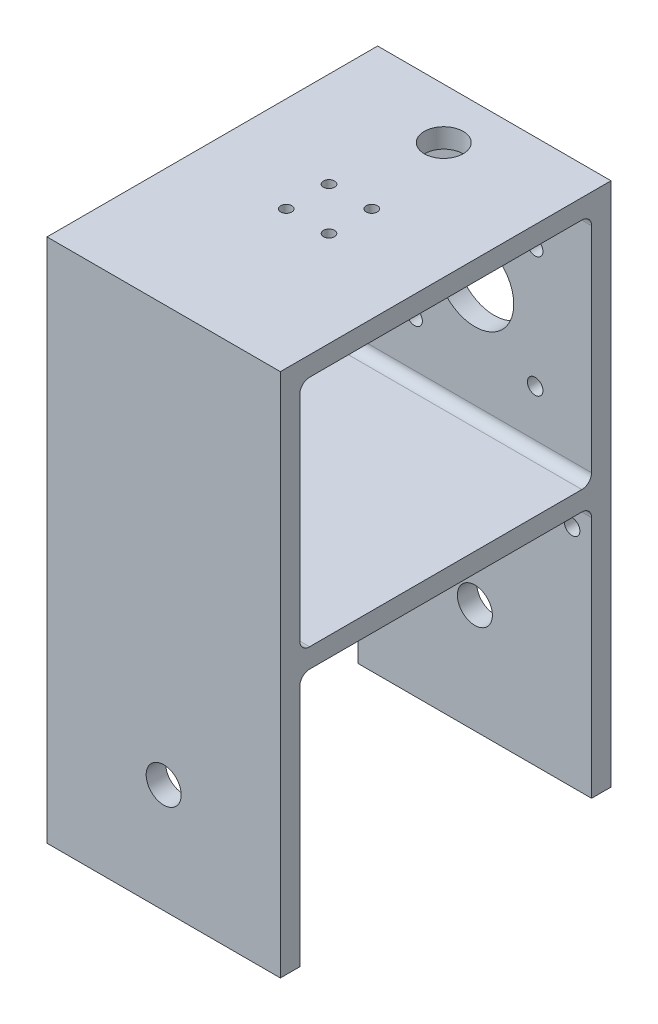
from build123d import *

# Parameters (mm, degrees)
BOSS_EXTRUDE1_DEPTH = 60
SKETCH2_W           = 75
SKETCH2_H           = 60
CUT_EXTRUDE1_DEPTH  = 60
CUT_EXTRUDE2_REACH  = 137
SKETCH3_R           = 1.425
SKETCH3_R_2         = 5
CUT_EXTRUDE3_REACH  = 87
SKETCH4_R           = 4.5
SKETCH4_R_2         = 10
SKETCH4_R_3         = 2
FILLET1_R           = 2.5
FILLET2_R           = 2.5
FILLET3_R           = 2.5
FILLET4_R           = 2.5
FILLET5_R           = 2.5
FILLET6_R           = 2.5
CUT_EXTRUDE4_REACH  = 87
SKETCH5_R           = 4.5


with BuildPart() as part:
    # Sketch1 → Boss-Extrude1 (new body)
    with BuildSketch(Plane(origin=(0, 0, 0), x_dir=(0, 0, -1), z_dir=(1, 0, 0))):
        Polygon((0, 0), (0, -135), (-5, -135), (-5, -70), (-80, -70), (-80, -135), (-85, -135), (-85, 0), align=None)
    extrude(amount=-BOSS_EXTRUDE1_DEPTH)

    # Sketch2 → Cut-Extrude1 (cut)
    with BuildSketch(Plane(origin=(0, 0, 0), x_dir=(0, 0, -1), z_dir=(1, 0, 0))):
        with Locations((-42.5, -35)):
            Rectangle(SKETCH2_W, SKETCH2_H)
    extrude(amount=-CUT_EXTRUDE1_DEPTH, mode=Mode.SUBTRACT)

    # Sketch3 → Cut-Extrude2 (cut, up to next)
    with BuildSketch(Plane(origin=(0, 0, 0), x_dir=(1, 0, 0), z_dir=(0, 1, 0)), mode=Mode.PRIVATE) as cut_extrude2_sk1:
        with Locations((-35.5, -37)):
            Circle(SKETCH3_R)
    cut_extrude2_tool1 = extrude(cut_extrude2_sk1.sketch, amount=-CUT_EXTRUDE2_REACH, mode=Mode.PRIVATE) & part.part
    add(cut_extrude2_tool1.solids().sort_by_distance((-35.5, 0, 37))[0], mode=Mode.SUBTRACT)
    # Sketch3 → Cut-Extrude2 (cut, up to next)
    with BuildSketch(Plane(origin=(0, 0, 0), x_dir=(1, 0, 0), z_dir=(0, 1, 0)), mode=Mode.PRIVATE) as cut_extrude2_sk2:
        with Locations((-24.5, -37)):
            Circle(SKETCH3_R)
    cut_extrude2_tool2 = extrude(cut_extrude2_sk2.sketch, amount=-CUT_EXTRUDE2_REACH, mode=Mode.PRIVATE) & part.part
    add(cut_extrude2_tool2.solids().sort_by_distance((-24.5, 0, 37))[0], mode=Mode.SUBTRACT)
    # Sketch3 → Cut-Extrude2 (cut, up to next)
    with BuildSketch(Plane(origin=(0, 0, 0), x_dir=(1, 0, 0), z_dir=(0, 1, 0)), mode=Mode.PRIVATE) as cut_extrude2_sk3:
        with Locations((-24.5, -48)):
            Circle(SKETCH3_R)
    cut_extrude2_tool3 = extrude(cut_extrude2_sk3.sketch, amount=-CUT_EXTRUDE2_REACH, mode=Mode.PRIVATE) & part.part
    add(cut_extrude2_tool3.solids().sort_by_distance((-24.5, 0, 48))[0], mode=Mode.SUBTRACT)
    # Sketch3 → Cut-Extrude2 (cut, up to next)
    with BuildSketch(Plane(origin=(0, 0, 0), x_dir=(1, 0, 0), z_dir=(0, 1, 0)), mode=Mode.PRIVATE) as cut_extrude2_sk4:
        with Locations((-35.5, -48)):
            Circle(SKETCH3_R)
    cut_extrude2_tool4 = extrude(cut_extrude2_sk4.sketch, amount=-CUT_EXTRUDE2_REACH, mode=Mode.PRIVATE) & part.part
    add(cut_extrude2_tool4.solids().sort_by_distance((-35.5, 0, 48))[0], mode=Mode.SUBTRACT)
    # Sketch3 → Cut-Extrude2 (cut, up to next)
    with BuildSketch(Plane(origin=(0, 0, 0), x_dir=(1, 0, 0), z_dir=(0, 1, 0)), mode=Mode.PRIVATE) as cut_extrude2_sk5:
        with Locations((-30, -13)):
            Circle(SKETCH3_R_2)
    cut_extrude2_tool5 = extrude(cut_extrude2_sk5.sketch, amount=-CUT_EXTRUDE2_REACH, mode=Mode.PRIVATE) & part.part
    add(cut_extrude2_tool5.solids().sort_by_distance((-30, 0, 13))[0], mode=Mode.SUBTRACT)

    # Sketch4 → Cut-Extrude3 (cut, up to next)
    with BuildSketch(Plane.XY, mode=Mode.PRIVATE) as cut_extrude3_sk1:
        with Locations((-30, -107)):
            Circle(SKETCH4_R)
    cut_extrude3_tool1 = extrude(cut_extrude3_sk1.sketch, amount=CUT_EXTRUDE3_REACH, mode=Mode.PRIVATE) & part.part
    add(cut_extrude3_tool1.solids().sort_by_distance((-30, -107, 0))[0], mode=Mode.SUBTRACT)
    # Sketch4 → Cut-Extrude3 (cut, up to next)
    with BuildSketch(Plane.XY, mode=Mode.PRIVATE) as cut_extrude3_sk2:
        with Locations((-30, -35)):
            Circle(SKETCH4_R_2)
    cut_extrude3_tool2 = extrude(cut_extrude3_sk2.sketch, amount=CUT_EXTRUDE3_REACH, mode=Mode.PRIVATE) & part.part
    add(cut_extrude3_tool2.solids().sort_by_distance((-30, -35, 0))[0], mode=Mode.SUBTRACT)
    # Sketch4 → Cut-Extrude3 (cut, up to next)
    with BuildSketch(Plane.XY, mode=Mode.PRIVATE) as cut_extrude3_sk3:
        with Locations((-5, -77)):
            Circle(SKETCH4_R_3)
    cut_extrude3_tool3 = extrude(cut_extrude3_sk3.sketch, amount=CUT_EXTRUDE3_REACH, mode=Mode.PRIVATE) & part.part
    add(cut_extrude3_tool3.solids().sort_by_distance((-5, -77, 0))[0], mode=Mode.SUBTRACT)
    # Sketch4 → Cut-Extrude3 (cut, up to next)
    with BuildSketch(Plane.XY, mode=Mode.PRIVATE) as cut_extrude3_sk4:
        with Locations((-55, -77)):
            Circle(SKETCH4_R_3)
    cut_extrude3_tool4 = extrude(cut_extrude3_sk4.sketch, amount=CUT_EXTRUDE3_REACH, mode=Mode.PRIVATE) & part.part
    add(cut_extrude3_tool4.solids().sort_by_distance((-55, -77, 0))[0], mode=Mode.SUBTRACT)
    # Sketch4 → Cut-Extrude3 (cut, up to next)
    with BuildSketch(Plane.XY, mode=Mode.PRIVATE) as cut_extrude3_sk5:
        with Locations((-14.5, -19.5)):
            Circle(SKETCH4_R_3)
    cut_extrude3_tool5 = extrude(cut_extrude3_sk5.sketch, amount=CUT_EXTRUDE3_REACH, mode=Mode.PRIVATE) & part.part
    add(cut_extrude3_tool5.solids().sort_by_distance((-14.5, -19.5, 0))[0], mode=Mode.SUBTRACT)
    # Sketch4 → Cut-Extrude3 (cut, up to next)
    with BuildSketch(Plane.XY, mode=Mode.PRIVATE) as cut_extrude3_sk6:
        with Locations((-45.5, -19.5)):
            Circle(SKETCH4_R_3)
    cut_extrude3_tool6 = extrude(cut_extrude3_sk6.sketch, amount=CUT_EXTRUDE3_REACH, mode=Mode.PRIVATE) & part.part
    add(cut_extrude3_tool6.solids().sort_by_distance((-45.5, -19.5, 0))[0], mode=Mode.SUBTRACT)
    # Sketch4 → Cut-Extrude3 (cut, up to next)
    with BuildSketch(Plane.XY, mode=Mode.PRIVATE) as cut_extrude3_sk7:
        with Locations((-45.5, -50.5)):
            Circle(SKETCH4_R_3)
    cut_extrude3_tool7 = extrude(cut_extrude3_sk7.sketch, amount=CUT_EXTRUDE3_REACH, mode=Mode.PRIVATE) & part.part
    add(cut_extrude3_tool7.solids().sort_by_distance((-45.5, -50.5, 0))[0], mode=Mode.SUBTRACT)
    # Sketch4 → Cut-Extrude3 (cut, up to next)
    with BuildSketch(Plane.XY, mode=Mode.PRIVATE) as cut_extrude3_sk8:
        with Locations((-14.5, -50.5)):
            Circle(SKETCH4_R_3)
    cut_extrude3_tool8 = extrude(cut_extrude3_sk8.sketch, amount=CUT_EXTRUDE3_REACH, mode=Mode.PRIVATE) & part.part
    add(cut_extrude3_tool8.solids().sort_by_distance((-14.5, -50.5, 0))[0], mode=Mode.SUBTRACT)

    # Fillet1
    fillet1_edges = [part.edges().sort_by_distance(p)[0] for p in [
        (-30, -70, 80),
    ]]
    fillet(fillet1_edges, radius=FILLET1_R)

    # Fillet2
    fillet2_edges = [part.edges().sort_by_distance(p)[0] for p in [
        (-30, -70, 5),
    ]]
    fillet(fillet2_edges, radius=FILLET2_R)

    # Fillet3
    fillet3_edges = [part.edges().sort_by_distance(p)[0] for p in [
        (-30, -65, 80),
    ]]
    fillet(fillet3_edges, radius=FILLET3_R)

    # Fillet4
    fillet4_edges = [part.edges().sort_by_distance(p)[0] for p in [
        (-30, -65, 5),
    ]]
    fillet(fillet4_edges, radius=FILLET4_R)

    # Fillet5
    fillet5_edges = [part.edges().sort_by_distance(p)[0] for p in [
        (-30, -5, 5),
    ]]
    fillet(fillet5_edges, radius=FILLET5_R)

    # Fillet6
    fillet6_edges = [part.edges().sort_by_distance(p)[0] for p in [
        (-30, -5, 80),
    ]]
    fillet(fillet6_edges, radius=FILLET6_R)

    # Sketch5 → Cut-Extrude4 (cut, up to next)
    with BuildSketch(Plane.XY.offset(85), mode=Mode.PRIVATE) as cut_extrude4_sk1:
        with Locations((-30, -107)):
            Circle(SKETCH5_R)
    cut_extrude4_tool1 = extrude(cut_extrude4_sk1.sketch, amount=-CUT_EXTRUDE4_REACH, mode=Mode.PRIVATE) & part.part
    add(cut_extrude4_tool1.solids().sort_by_distance((-30, -107, 85))[0], mode=Mode.SUBTRACT)


solid = part.part
